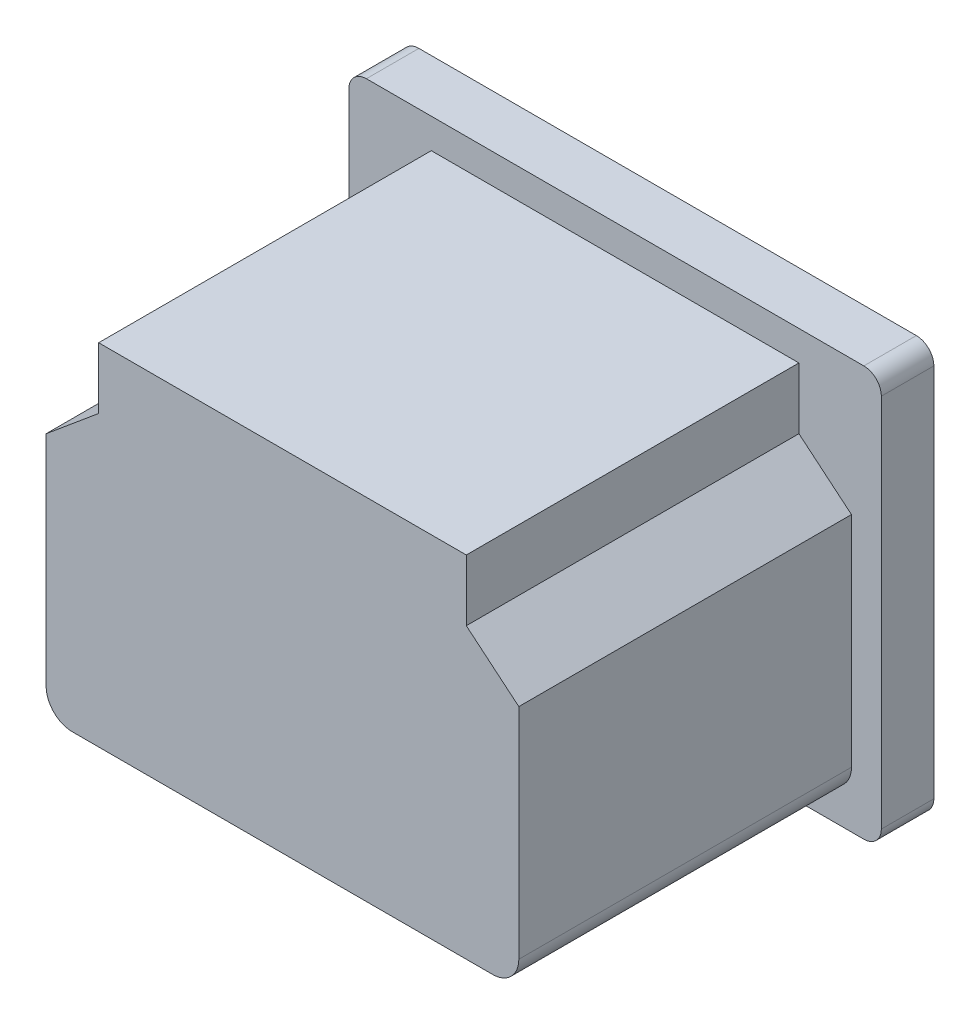
from build123d import *

# Parameters (mm, degrees)
EXTRUDE_1_DEPTH     = 3
EXTRUDE_2_DEPTH     = 19
CUT_EXTRUDE_1_DEPTH = 17.5
SKETCH_4_W          = 2
SKETCH_4_H          = 4
EXTRUDE_3_DEPTH     = 12.5
EXTRUDE_4_DEPTH     = 4
CUT_EXTRUDE_2_DEPTH = 4


with BuildPart() as part:
    # 草图1 → 凸台-拉伸1 (new body)
    with BuildSketch(Plane.XY):
        with BuildLine():
            Line((-14.207106781, 11.707106781), (14.207106781, 11.707106781))
            ThreePointArc((14.207106781, 11.707106781), (14.914213562, 11.414213562), (15.207106781, 10.707106781))
            Line((15.207106781, 10.707106781), (15.207106781, -10.707106781))
            ThreePointArc((15.207106781, -10.707106781), (14.914213562, -11.414213562), (14.207106781, -11.707106781))
            Line((14.207106781, -11.707106781), (-14.207106781, -11.707106781))
            ThreePointArc((-14.207106781, -11.707106781), (-14.914213562, -11.414213562), (-15.207106781, -10.707106781))
            Line((-15.207106781, -10.707106781), (-15.207106781, 10.707106781))
            ThreePointArc((-15.207106781, 10.707106781), (-14.914213562, 11.414213562), (-14.207106781, 11.707106781))
        make_face()
    extrude(amount=EXTRUDE_1_DEPTH)

    # 草图2 → 凸台-拉伸2 (add)
    with BuildSketch(Plane.XY.offset(3)):
        with BuildLine():
            Line((-10.5, 10), (-10.5, 6.5))
            Line((-10.5, 6.5), (-13.5, 4))
            Line((-13.5, 4), (-13.5, -8.5))
            ThreePointArc((-13.5, -8.5), (-13.060660172, -9.560660172), (-12, -10))
            Line((-12, -10), (12, -10))
            ThreePointArc((12, -10), (13.060660172, -9.560660172), (13.5, -8.5))
            Line((13.5, -8.5), (13.5, 4))
            Line((13.5, 4), (10.5, 6.5))
            Line((10.5, 6.5), (10.5, 10))
            Line((10.5, 10), (-10.5, 10))
        make_face()
    extrude(amount=EXTRUDE_2_DEPTH)

    # 草图3 → 切除-拉伸1 (cut)
    with BuildSketch(Plane(origin=(0, 0, 0), x_dir=(-1, 0, 0), z_dir=(0, 0, -1))):
        with BuildLine():
            Line((12, -6.525638569), (12, 1.761252493))
            ThreePointArc((12, 1.761252493), (11.959963562, 1.957297186), (11.846265914, 2.121946154))
            Line((11.846265914, 2.121946154), (5.89511077, 7.835055092))
            ThreePointArc((5.89511077, 7.835055092), (5.735463679, 7.938229317), (5.548844856, 7.974361431))
            Line((5.548844856, 7.974361431), (-5.548844856, 7.974361431))
            ThreePointArc((-5.548844856, 7.974361431), (-5.735463679, 7.938229317), (-5.89511077, 7.835055092))
            Line((-5.89511077, 7.835055092), (-11.846265914, 2.121946154))
            ThreePointArc((-11.846265914, 2.121946154), (-11.959963562, 1.957297186), (-12, 1.761252493))
            Line((-12, 1.761252493), (-12, -6.525638569))
            ThreePointArc((-12, -6.525638569), (-11.560660172, -7.58629874), (-10.5, -8.025638569))
            Line((-10.5, -8.025638569), (10.5, -8.025638569))
            ThreePointArc((10.5, -8.025638569), (11.560660172, -7.58629874), (12, -6.525638569))
        make_face()
    extrude(amount=-CUT_EXTRUDE_1_DEPTH, mode=Mode.SUBTRACT)

    # 草图4 → 凸台-拉伸3 (add)
    with BuildSketch(Plane(origin=(0, 0, 17.5), x_dir=(-1, 0, 0), z_dir=(0, 0, -1))):
        with Locations((-7, -4.041451884)):
            Rectangle(SKETCH_4_W, SKETCH_4_H)
        with Locations((0, 3.099976544)):
            Rectangle(SKETCH_4_W, SKETCH_4_H)
        with Locations((7, -4.041451884)):
            Rectangle(SKETCH_4_W, SKETCH_4_H)
    extrude(amount=EXTRUDE_3_DEPTH)

    # 草图5 → 凸台-拉伸4 (add)
    with BuildSketch(Plane.XZ.offset(-1.099976544)):
        Polygon((1, 5), (-1, 5), (-0.5, 2.5), (0.5, 2.5), align=None)
    extrude(amount=-EXTRUDE_4_DEPTH)

    # 草图6 → 切除-拉伸2 (cut)
    with BuildSketch(Plane.XZ.offset(6.041451884)):
        Polygon((8, 5), (8, 7.5), (7.5, 5), align=None)
        Polygon((6.5, 5), (6, 5), (6, 7.5), align=None)
        Polygon((-6, 5), (-6, 7.5), (-6.5, 5), align=None)
        Polygon((-7.5, 5), (-8, 5), (-8, 7.5), align=None)
    extrude(amount=-CUT_EXTRUDE_2_DEPTH, mode=Mode.SUBTRACT)


solid = part.part
